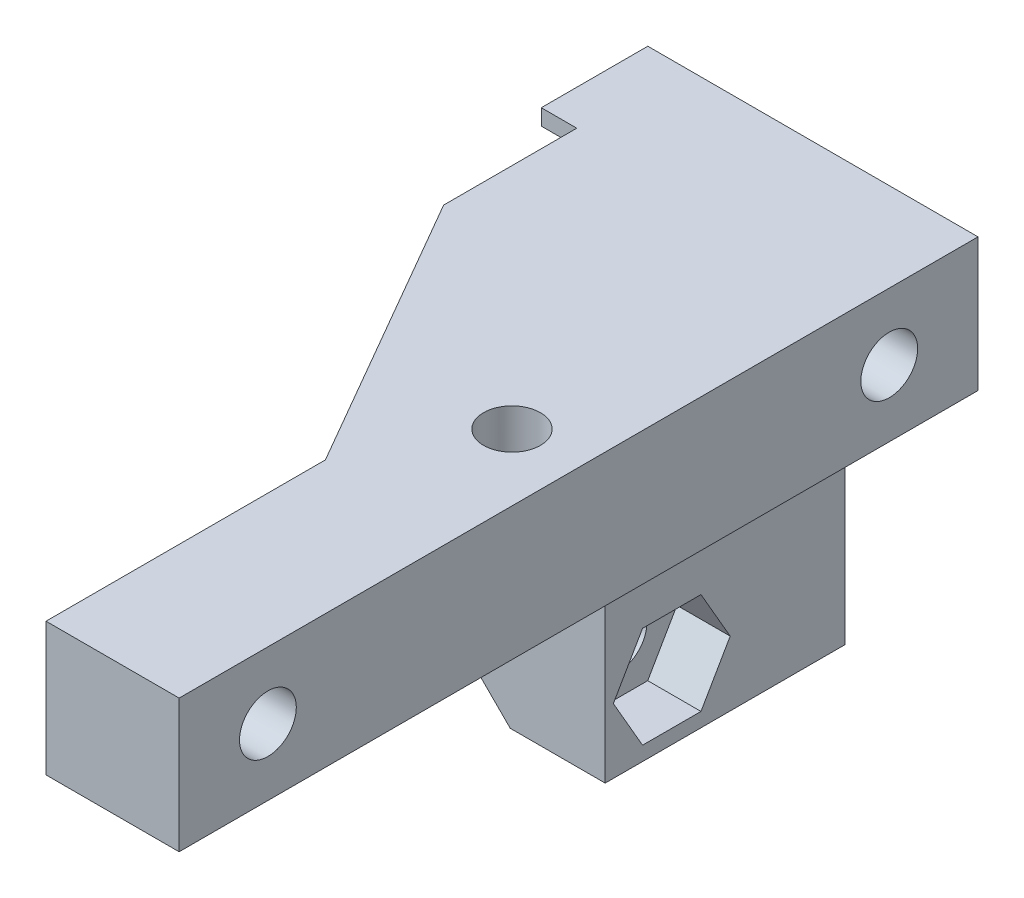
from build123d import *

# Parameters (mm, degrees)
SALIENTE_EXTRUIR1_DEPTH = 6
SALIENTE_EXTRUIR2_DEPTH = 7.5
SALIENTE_EXTRUIR3_DEPTH = 7.5
CROQUIS4_W              = 7.5
CROQUIS4_H              = 7.5
SALIENTE_EXTRUIR4_DEPTH = 31.5
CORTAR_EXTRUIR1_REACH   = 20.6
CROQUIS5_R              = 1.6
CORTAR_EXTRUIR2_DEPTH   = 14.1
CORTAR_EXTRUIR3_DEPTH   = 3
CORTAR_EXTRUIR4_REACH   = 25.65
CROQUIS8_R              = 1.6
CORTAR_EXTRUIR5_DEPTH   = 3
CORTAR_EXTRUIR6_REACH   = 13.1
CROQUIS10_R             = 1.6
CORTAR_EXTRUIR7_DEPTH   = 3


with BuildPart() as part:
    # Croquis1 → Saliente-Extruir1 (new body)
    with BuildSketch(Plane.XY):
        Polygon((0, 0), (16.6, 0), (16.6, 7.5), (9.1, 7.5), (9.1, 23.65), (3.75, 23.65), (-2, 23.65), (-2, 0), align=None)
    extrude(amount=SALIENTE_EXTRUIR1_DEPTH)

    # Croquis2 → Saliente-Extruir2 (add)
    with BuildSketch(Plane.XY.offset(6)):
        Polygon((0, 0), (0, 19.9), (3.75, 23.65), (9.1, 23.65), (9.1, 7.5), (16.6, 7.5), (16.6, 0), align=None)
    extrude(amount=SALIENTE_EXTRUIR2_DEPTH)

    # Croquis3 → Saliente-Extruir3 (add)
    with BuildSketch(Plane.XZ):
        Polygon((0, 13.5), (9.1, 29.261662349), (9.1, 13.5), align=None)
    extrude(amount=-SALIENTE_EXTRUIR3_DEPTH)

    # Croquis4 → Saliente-Extruir4 (add)
    with BuildSketch(Plane.XY.offset(13.5)):
        with Locations((12.85, 3.75)):
            Rectangle(CROQUIS4_W, CROQUIS4_H)
    extrude(amount=SALIENTE_EXTRUIR4_DEPTH)

    # Croquis5 → Cortar-Extruir1 (cut, up to next)
    with BuildSketch(Plane(origin=(16.6, 0, 0), x_dir=(0, 0, -1), z_dir=(1, 0, 0)), mode=Mode.PRIVATE) as cortar_extruir1_sk1:
        with Locations((-5, 3.75)):
            Circle(CROQUIS5_R)
    cortar_extruir1_tool1 = extrude(cortar_extruir1_sk1.sketch, amount=-CORTAR_EXTRUIR1_REACH, mode=Mode.PRIVATE) & part.part
    add(cortar_extruir1_tool1.solids().sort_by_distance((16.6, 3.75, 5))[0], mode=Mode.SUBTRACT)
    # Croquis5 → Cortar-Extruir1 (cut, up to next)
    with BuildSketch(Plane(origin=(16.6, 0, 0), x_dir=(0, 0, -1), z_dir=(1, 0, 0)), mode=Mode.PRIVATE) as cortar_extruir1_sk2:
        with Locations((-40, 3.75)):
            Circle(CROQUIS5_R)
    cortar_extruir1_tool2 = extrude(cortar_extruir1_sk2.sketch, amount=-CORTAR_EXTRUIR1_REACH, mode=Mode.PRIVATE) & part.part
    add(cortar_extruir1_tool2.solids().sort_by_distance((16.6, 3.75, 40))[0], mode=Mode.SUBTRACT)

    # Croquis6 → Cortar-Extruir2 (cut)
    with BuildSketch(Plane.ZY.offset(2)):
        Polygon((3.354551733, 0.9), (6.645448267, 0.9), (8.290896534, 3.75), (6.645448267, 6.6), (3.354551733, 6.6), (1.709103466, 3.75), align=None)
    extrude(amount=-CORTAR_EXTRUIR2_DEPTH, mode=Mode.SUBTRACT)

    # Croquis7 → Cortar-Extruir3 (cut)
    with BuildSketch(Plane.ZY.offset(-9.1)):
        Polygon((38.354551733, 0.9), (41.645448267, 0.9), (43.290896534, 3.75), (41.645448267, 6.6), (38.354551733, 6.6), (36.709103466, 3.75), align=None)
    extrude(amount=-CORTAR_EXTRUIR3_DEPTH, mode=Mode.SUBTRACT)

    # Croquis8 → Cortar-Extruir4 (cut, up to next)
    with BuildSketch(Plane.XZ, mode=Mode.PRIVATE) as cortar_extruir4_sk1:
        with Locations((12.85, 22.5)):
            Circle(CROQUIS8_R)
    cortar_extruir4_tool1 = extrude(cortar_extruir4_sk1.sketch, amount=-CORTAR_EXTRUIR4_REACH, mode=Mode.PRIVATE) & part.part
    add(cortar_extruir4_tool1.solids().sort_by_distance((12.85, 0, 22.5))[0], mode=Mode.SUBTRACT)

    # Croquis9 → Cortar-Extruir5 (cut)
    with BuildSketch(Plane(origin=(0, 7.5, 0), x_dir=(1, 0, 0), z_dir=(0, 1, 0))):
        Polygon((15.7, -20.854551733), (12.85, -19.209103466), (10, -20.854551733), (10, -24.145448267), (12.85, -25.790896534), (15.7, -24.145448267), align=None)
    extrude(amount=-CORTAR_EXTRUIR5_DEPTH, mode=Mode.SUBTRACT)

    # Croquis10 → Cortar-Extruir6 (cut, up to next)
    with BuildSketch(Plane(origin=(9.1, 0, 0), x_dir=(0, 0, -1), z_dir=(1, 0, 0)), mode=Mode.PRIVATE) as cortar_extruir6_sk1:
        with Locations((-9.75, 20)):
            Circle(CROQUIS10_R)
    cortar_extruir6_tool1 = extrude(cortar_extruir6_sk1.sketch, amount=-CORTAR_EXTRUIR6_REACH, mode=Mode.PRIVATE) & part.part
    add(cortar_extruir6_tool1.solids().sort_by_distance((9.1, 20, 9.75))[0], mode=Mode.SUBTRACT)

    # Croquis11 → Cortar-Extruir7 (cut)
    with BuildSketch(Plane(origin=(9.1, 0, 0), x_dir=(0, 0, -1), z_dir=(1, 0, 0))):
        Polygon((-8.104551733, 22.85), (-11.395448267, 22.85), (-13.040896534, 20), (-11.395448267, 17.15), (-8.104551733, 17.15), (-6.459103466, 20), align=None)
    extrude(amount=-CORTAR_EXTRUIR7_DEPTH, mode=Mode.SUBTRACT)


with BuildPart() as body_2:
    # Simetría1: mirrored copy
    add(part.part.mirror(Plane.ZX))


solid = body_2.part
